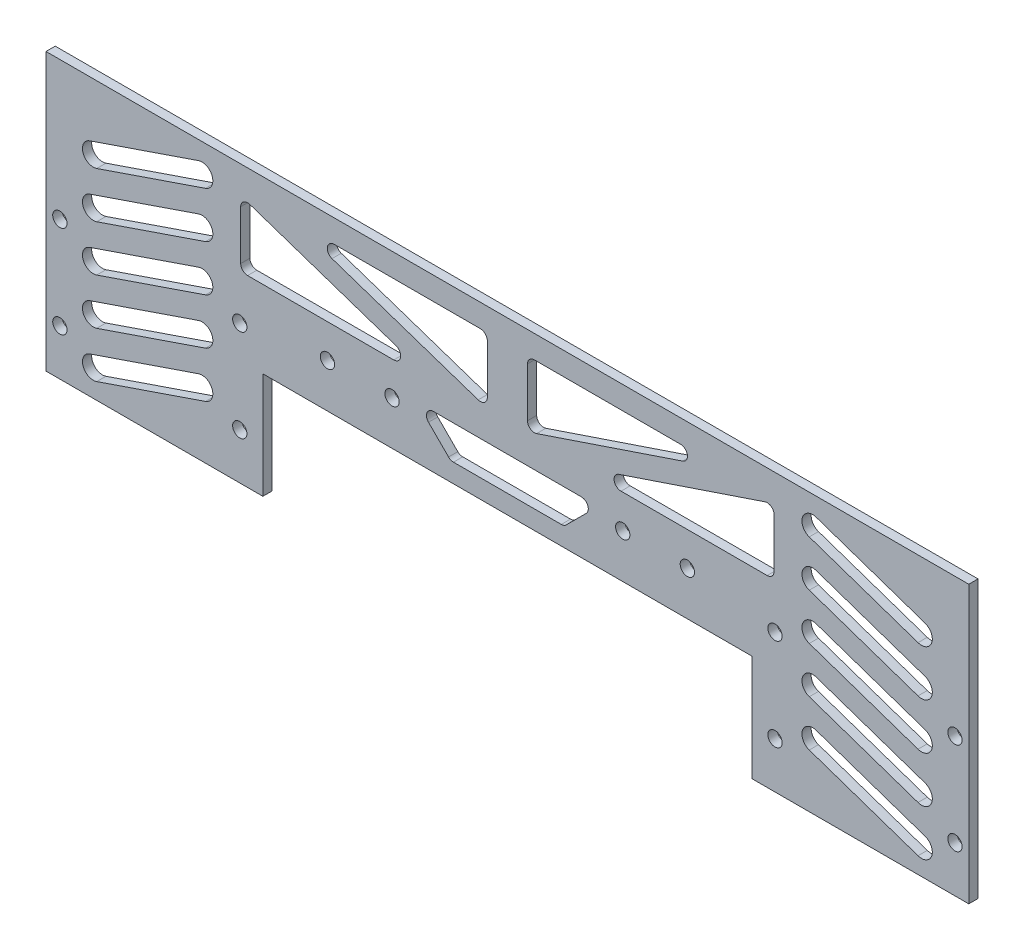
from build123d import *

# Parameters (mm, degrees)
SKETCH_1_R      = 1.55
EXTRUDE_1_DEPTH = 2


with BuildPart() as part:
    # 草图1 → 凸台-拉伸1 (new body)
    with BuildSketch(Plane.XY):
        Polygon((69.118055556, 5.822916667), (69.118055556, -30.177083333), (22.118055556, -30.177083333), (22.118055556, -7.177083333), (-83.881944444, -7.177083333), (-83.881944444, -30.177083333), (-130.881944444, -30.177083333), (-130.881944444, 5.822916667), (-130.881944444, 29.822916667), (69.118055556, 29.822916667), align=None)
        with Locations((-127.881944444, -0.177083333)):
            Circle(SKETCH_1_R, mode=Mode.SUBTRACT)
        with Locations((-127.881944444, -20.177083333)):
            Circle(SKETCH_1_R, mode=Mode.SUBTRACT)
        with Locations((-88.881944444, -0.177083333)):
            Circle(SKETCH_1_R, mode=Mode.SUBTRACT)
        with Locations((-88.881944444, -20.177083333)):
            Circle(SKETCH_1_R, mode=Mode.SUBTRACT)
        with Locations((27.118055556, -0.177083333)):
            Circle(SKETCH_1_R, mode=Mode.SUBTRACT)
        with Locations((27.118055556, -20.177083333)):
            Circle(SKETCH_1_R, mode=Mode.SUBTRACT)
        with Locations((66.118055556, -0.177083333)):
            Circle(SKETCH_1_R, mode=Mode.SUBTRACT)
        with Locations((66.118055556, -20.177083333)):
            Circle(SKETCH_1_R, mode=Mode.SUBTRACT)
        with Locations((-69.881944444, 2.322916667)):
            Circle(SKETCH_1_R, mode=Mode.SUBTRACT)
        with Locations((-55.881944444, 2.322916667)):
            Circle(SKETCH_1_R, mode=Mode.SUBTRACT)
        with Locations((-5.881944444, 2.322916667)):
            Circle(SKETCH_1_R, mode=Mode.SUBTRACT)
        with Locations((8.118055556, 2.322916667)):
            Circle(SKETCH_1_R, mode=Mode.SUBTRACT)
        with BuildLine():
            Line((-96.308316621, 21.419007892), (-119.878819488, 13.358099985))
            ThreePointArc((-119.878819488, 13.358099985), (-122.854752457, 14.817267118), (-121.395585324, 17.793200088))
            Line((-121.395585324, 17.793200088), (-97.825082457, 25.854107995))
            ThreePointArc((-97.825082457, 25.854107995), (-94.849149487, 24.394940861), (-96.308316621, 21.419007892))
        make_face(mode=Mode.SUBTRACT)
        with BuildLine():
            Line((-96.308316621, 11.419007892), (-119.878819488, 3.358099985))
            ThreePointArc((-119.878819488, 3.358099985), (-122.854752457, 4.817267118), (-121.395585324, 7.793200088))
            Line((-121.395585324, 7.793200088), (-97.825082457, 15.854107995))
            ThreePointArc((-97.825082457, 15.854107995), (-94.849149487, 14.394940861), (-96.308316621, 11.419007892))
        make_face(mode=Mode.SUBTRACT)
        with BuildLine():
            Line((-96.308316621, 1.419007892), (-119.878819488, -6.641900015))
            ThreePointArc((-119.878819488, -6.641900015), (-122.854752457, -5.182732882), (-121.395585324, -2.206799912))
            Line((-121.395585324, -2.206799912), (-97.825082457, 5.854107995))
            ThreePointArc((-97.825082457, 5.854107995), (-94.849149487, 4.394940861), (-96.308316621, 1.419007892))
        make_face(mode=Mode.SUBTRACT)
        with BuildLine():
            Line((-96.308316621, -8.580992108), (-119.878819488, -16.641900015))
            ThreePointArc((-119.878819488, -16.641900015), (-122.854752457, -15.182732882), (-121.395585324, -12.206799912))
            Line((-121.395585324, -12.206799912), (-97.825082457, -4.145892005))
            ThreePointArc((-97.825082457, -4.145892005), (-94.849149487, -5.605059139), (-96.308316621, -8.580992108))
        make_face(mode=Mode.SUBTRACT)
        with BuildLine():
            Line((-96.308316621, -18.580992108), (-119.878819488, -26.641900015))
            ThreePointArc((-119.878819488, -26.641900015), (-122.854752457, -25.182732882), (-121.395585324, -22.206799912))
            Line((-121.395585324, -22.206799912), (-97.825082457, -14.145892005))
            ThreePointArc((-97.825082457, -14.145892005), (-94.849149487, -15.605059139), (-96.308316621, -18.580992108))
        make_face(mode=Mode.SUBTRACT)
        with BuildLine():
            Line((34.544427732, -18.580992108), (58.114930599, -26.641900015))
            ThreePointArc((58.114930599, -26.641900015), (61.090863569, -25.182732882), (59.631696435, -22.206799912))
            Line((59.631696435, -22.206799912), (36.061193568, -14.145892005))
            ThreePointArc((36.061193568, -14.145892005), (33.085260599, -15.605059139), (34.544427732, -18.580992108))
        make_face(mode=Mode.SUBTRACT)
        with BuildLine():
            Line((34.544427732, -8.580992108), (58.114930599, -16.641900015))
            ThreePointArc((58.114930599, -16.641900015), (61.090863569, -15.182732882), (59.631696435, -12.206799912))
            Line((59.631696435, -12.206799912), (36.061193568, -4.145892005))
            ThreePointArc((36.061193568, -4.145892005), (33.085260599, -5.605059139), (34.544427732, -8.580992108))
        make_face(mode=Mode.SUBTRACT)
        with BuildLine():
            Line((34.544427732, 1.419007892), (58.114930599, -6.641900015))
            ThreePointArc((58.114930599, -6.641900015), (61.090863569, -5.182732882), (59.631696435, -2.206799912))
            Line((59.631696435, -2.206799912), (36.061193568, 5.854107995))
            ThreePointArc((36.061193568, 5.854107995), (33.085260599, 4.394940861), (34.544427732, 1.419007892))
        make_face(mode=Mode.SUBTRACT)
        with BuildLine():
            Line((34.544427732, 11.419007892), (58.114930599, 3.358099985))
            ThreePointArc((58.114930599, 3.358099985), (61.090863569, 4.817267118), (59.631696435, 7.793200088))
            Line((59.631696435, 7.793200088), (36.061193568, 15.854107995))
            ThreePointArc((36.061193568, 15.854107995), (33.085260599, 14.394940861), (34.544427732, 11.419007892))
        make_face(mode=Mode.SUBTRACT)
        with BuildLine():
            Line((34.544427732, 21.419007892), (58.114930599, 13.358099985))
            ThreePointArc((58.114930599, 13.358099985), (61.090863569, 14.817267118), (59.631696435, 17.793200088))
            Line((59.631696435, 17.793200088), (36.061193568, 25.854107995))
            ThreePointArc((36.061193568, 25.854107995), (33.085260599, 24.394940861), (34.544427732, 21.419007892))
        make_face(mode=Mode.SUBTRACT)
        with BuildLine():
            Line((-86.707081272, 23.202972479), (-55.025491003, 12.527575239))
            ThreePointArc((-55.025491003, 12.527575239), (-54.024230917, 10.863417849), (-55.504468546, 9.60610399))
            Line((-55.504468546, 9.60610399), (-87.186058815, 9.60610399))
            ThreePointArc((-87.186058815, 9.60610399), (-88.246718986, 10.045443818), (-88.686058815, 11.10610399))
            Line((-88.686058815, 11.10610399), (-88.686058815, 21.781501229))
            ThreePointArc((-88.686058815, 21.781501229), (-88.061139864, 22.99979231), (-86.707081272, 23.202972479))
        make_face(mode=Mode.SUBTRACT)
        with BuildLine():
            Line((-68.415657461, 24.859225404), (-36.734067193, 24.859225404))
            ThreePointArc((-36.734067193, 24.859225404), (-35.673407021, 24.419885576), (-35.234067193, 23.359225404))
            Line((-35.234067193, 23.359225404), (-35.234067193, 12.683828165))
            ThreePointArc((-35.234067193, 12.683828165), (-35.858986143, 11.465537084), (-37.213044735, 11.262356915))
            Line((-37.213044735, 11.262356915), (-68.894635004, 21.937754155))
            ThreePointArc((-68.894635004, 21.937754155), (-69.89589509, 23.601911545), (-68.415657461, 24.859225404))
        make_face(mode=Mode.SUBTRACT)
        with BuildLine():
            Line((26.922169926, 21.781501229), (26.922169926, 11.10610399))
            ThreePointArc((26.922169926, 11.10610399), (26.482830097, 10.045443818), (25.422169926, 9.60610399))
            Line((25.422169926, 9.60610399), (-6.259420343, 9.60610399))
            ThreePointArc((-6.259420343, 9.60610399), (-7.739657972, 10.863417849), (-6.738397886, 12.527575239))
            Line((-6.738397886, 12.527575239), (24.943192383, 23.202972479))
            ThreePointArc((24.943192383, 23.202972479), (26.297250975, 22.99979231), (26.922169926, 21.781501229))
        make_face(mode=Mode.SUBTRACT)
        with BuildLine():
            Line((7.130746115, 21.937754155), (-24.550844154, 11.262356915))
            ThreePointArc((-24.550844154, 11.262356915), (-25.904902746, 11.465537084), (-26.529821696, 12.683828165))
            Line((-26.529821696, 12.683828165), (-26.529821696, 23.359225404))
            ThreePointArc((-26.529821696, 23.359225404), (-26.090481868, 24.419885576), (-25.029821696, 24.859225404))
            Line((-25.029821696, 24.859225404), (6.651768572, 24.859225404))
            ThreePointArc((6.651768572, 24.859225404), (8.132006201, 23.601911545), (7.130746115, 21.937754155))
        make_face(mode=Mode.SUBTRACT)
        with BuildLine():
            Line((-14.846833492, 4.237725323), (-46.917055397, 4.237725323))
            ThreePointArc((-46.917055397, 4.237725323), (-48.302874696, 3.311750471), (-47.977715569, 1.677065151))
            Line((-47.977715569, 1.677065151), (-43.630536244, -2.670114174))
            ThreePointArc((-43.630536244, -2.670114174), (-43.14390122, -2.995273301), (-42.569876072, -3.109454002))
            Line((-42.569876072, -3.109454002), (-19.194012817, -3.109454002))
            ThreePointArc((-19.194012817, -3.109454002), (-18.619987668, -2.995273301), (-18.133352645, -2.670114174))
            Line((-18.133352645, -2.670114174), (-13.78617332, 1.677065151))
            ThreePointArc((-13.78617332, 1.677065151), (-13.461014193, 3.311750471), (-14.846833492, 4.237725323))
        make_face(mode=Mode.SUBTRACT)
    extrude(amount=EXTRUDE_1_DEPTH)


solid = part.part
